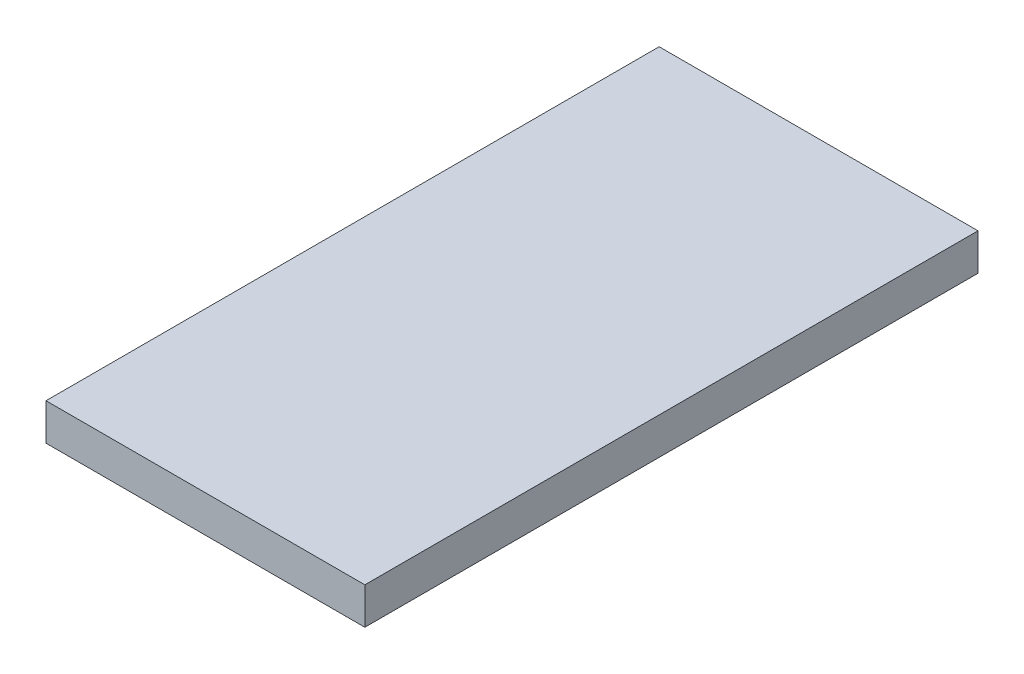
from build123d import *

# Parameters (mm, degrees)
CROQUIS1_W              = 26
CROQUIS1_H              = 50
SALIENTE_EXTRUIR1_DEPTH = 3


with BuildPart() as part:
    # Croquis1 → Saliente-Extruir1 (new body)
    with BuildSketch(Plane(origin=(0, 0, 0), x_dir=(1, 0, 0), z_dir=(0, 1, 0))):
        with Locations((13, 25)):
            Rectangle(CROQUIS1_W, CROQUIS1_H)
    extrude(amount=SALIENTE_EXTRUIR1_DEPTH)


solid = part.part
